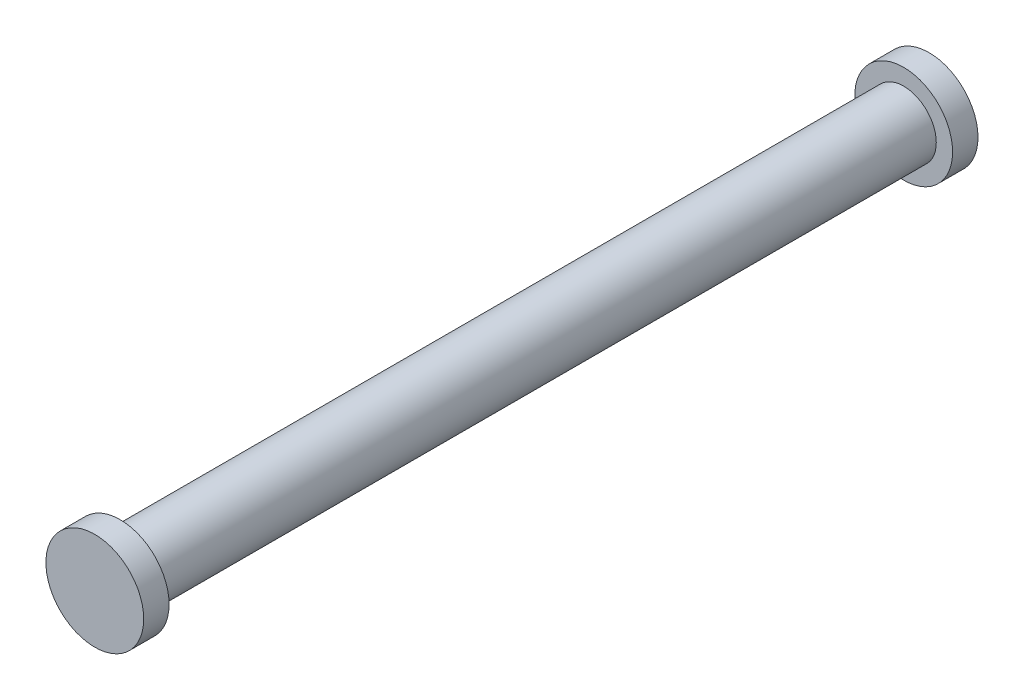
from build123d import *

# Parameters (mm, degrees)
SKETCH1_R           = 7.5
SKETCH1_R_2         = 5
BOSS_EXTRUDE1_DEPTH = 128
CUT_EXTRUDE1_START  = 3.9
SKETCH1_6_R         = 7.5
SKETCH1_6_R_2       = 5
CUT_EXTRUDE1_DEPTH  = 120.2


with BuildPart() as part:
    # Sketch1 → Boss-Extrude1 (new body)
    with BuildSketch(Plane.XY):
        Circle(SKETCH1_R)
        Circle(SKETCH1_R_2, mode=Mode.SUBTRACT)
        Circle(SKETCH1_R_2)
    extrude(amount=BOSS_EXTRUDE1_DEPTH)

    # Sketch1_6 → Cut-Extrude1 (cut)
    with BuildSketch(Plane.XY.offset(CUT_EXTRUDE1_START)):
        Circle(SKETCH1_6_R)
        Circle(SKETCH1_6_R_2, mode=Mode.SUBTRACT)
    extrude(amount=CUT_EXTRUDE1_DEPTH, mode=Mode.SUBTRACT)


solid = part.part
